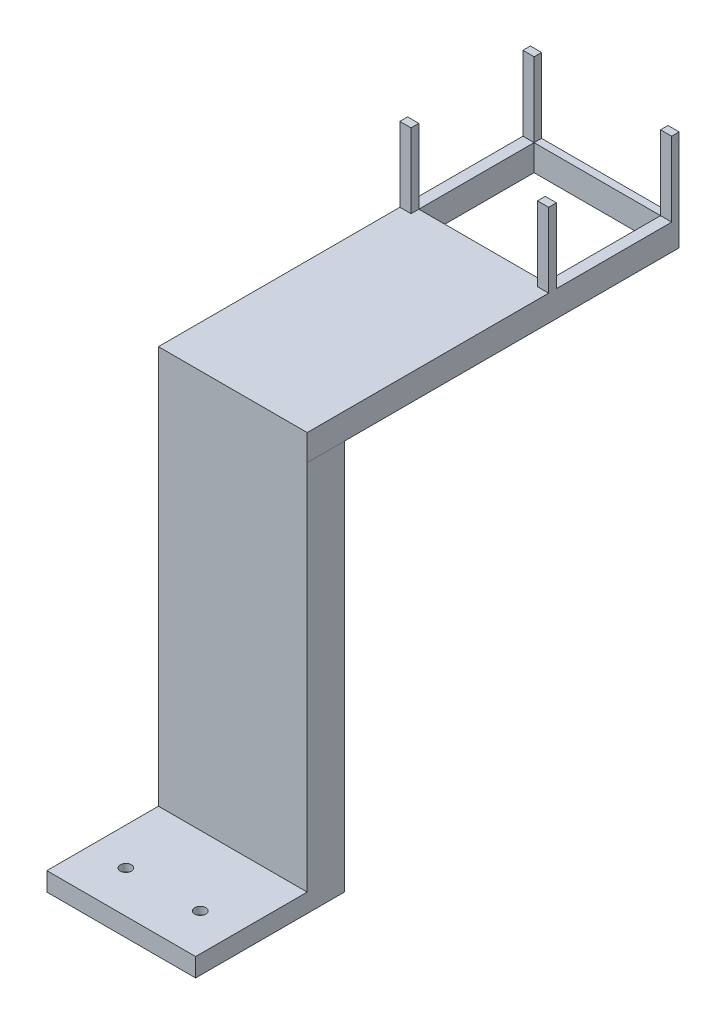
from build123d import *

# Parameters (mm, degrees)
SKETCH1_W           = 40
SKETCH1_H           = 40
BOSS_EXTRUDE1_DEPTH = 5
SKETCH2_R           = 1.5
CUT_EXTRUDE1_DEPTH  = 2
SKETCH5_W           = 40
SKETCH5_H           = 10
BOSS_EXTRUDE2_DEPTH = 100
SKETCH6_W           = 40.003445824
SKETCH6_H           = 100
BOSS_EXTRUDE3_DEPTH = 7
SKETCH7_W           = 34
SKETCH7_H           = 31
CUT_EXTRUDE2_DEPTH  = 100
SKETCH8_W           = 3.001722912
SKETCH8_H           = 2
SKETCH8_H_2         = 2.093229538
BOSS_EXTRUDE4_DEPTH = 20


with BuildPart() as part:
    # Sketch1 → Boss-Extrude1 (new body)
    with BuildSketch(Plane(origin=(0, 0, 0), x_dir=(1, 0, 0), z_dir=(0, 1, 0))):
        with Locations((20, 20)):
            Rectangle(SKETCH1_W, SKETCH1_H)
    extrude(amount=BOSS_EXTRUDE1_DEPTH)

    # Sketch2 → Cut-Extrude1 (cut)
    with BuildSketch(Plane(origin=(0, 5, 0), x_dir=(1, 0, 0), z_dir=(0, 1, 0))):
        with Locations((10, 11.251726065)):
            Circle(SKETCH2_R)
        with Locations((30, 11.251726065)):
            Circle(SKETCH2_R)
    extrude(amount=-CUT_EXTRUDE1_DEPTH, mode=Mode.SUBTRACT)

    # Sketch5 → Boss-Extrude2 (add)
    with BuildSketch(Plane(origin=(0, 5, 0), x_dir=(1, 0, 0), z_dir=(0, 1, 0))):
        with Locations((20, 35)):
            Rectangle(SKETCH5_W, SKETCH5_H)
    extrude(amount=BOSS_EXTRUDE2_DEPTH)

    # Sketch6 → Boss-Extrude3 (add)
    with BuildSketch(Plane(origin=(0, 105, 0), x_dir=(1, 0, 0), z_dir=(0, 1, 0))):
        with Locations((20.001722912, 80)):
            Rectangle(SKETCH6_W, SKETCH6_H)
    extrude(amount=BOSS_EXTRUDE3_DEPTH)

    # Sketch7 → Cut-Extrude2 (cut)
    with BuildSketch(Plane(origin=(0, 112, 0), x_dir=(1, 0, 0), z_dir=(0, 1, 0))):
        with Locations((20.001722912, 112.5)):
            Rectangle(SKETCH7_W, SKETCH7_H)
    extrude(amount=-CUT_EXTRUDE2_DEPTH, mode=Mode.SUBTRACT)

    # Sketch8 → Boss-Extrude4 (add)
    with BuildSketch(Plane(origin=(0, 112, 0), x_dir=(1, 0, 0), z_dir=(0, 1, 0))):
        with Locations((38.502584368, 129)):
            Rectangle(SKETCH8_W, SKETCH8_H)
        with Locations((1.500861456, 129)):
            Rectangle(SKETCH8_W, SKETCH8_H)
        with Locations((1.500861456, 95.953385231)):
            Rectangle(SKETCH8_W, SKETCH8_H_2)
        with Locations((38.502584368, 95.953385231)):
            Rectangle(SKETCH8_W, SKETCH8_H_2)
    extrude(amount=BOSS_EXTRUDE4_DEPTH)


solid = part.part
